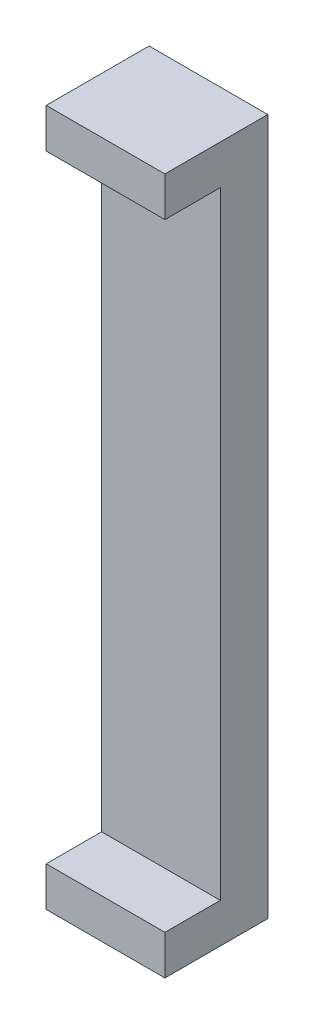
from build123d import *

# Parameters (mm, degrees)
SKETCH1_W           = 15
SKETCH1_H           = 88
BOSS_EXTRUDE1_DEPTH = 3
SKETCH2_W           = 15
SKETCH2_H           = 5
BOSS_EXTRUDE2_DEPTH = 10
SKETCH3_W           = 15
SKETCH3_H           = 5
BOSS_EXTRUDE3_DEPTH = 10


with BuildPart() as part:
    # Sketch1 → Boss-Extrude1 (new body, symmetric)
    with BuildSketch(Plane.XY):
        with Locations((0, 44)):
            Rectangle(SKETCH1_W, SKETCH1_H)
    extrude(amount=BOSS_EXTRUDE1_DEPTH, both=True)

    # Sketch2 → Boss-Extrude2 (add)
    with BuildSketch(Plane.XY):
        with Locations((0, 2.5)):
            Rectangle(SKETCH2_W, SKETCH2_H)
    extrude(amount=BOSS_EXTRUDE2_DEPTH)

    # Sketch3 → Boss-Extrude3 (add)
    with BuildSketch(Plane.XY):
        with Locations((0, 85.5)):
            Rectangle(SKETCH3_W, SKETCH3_H)
    extrude(amount=BOSS_EXTRUDE3_DEPTH)


solid = part.part
